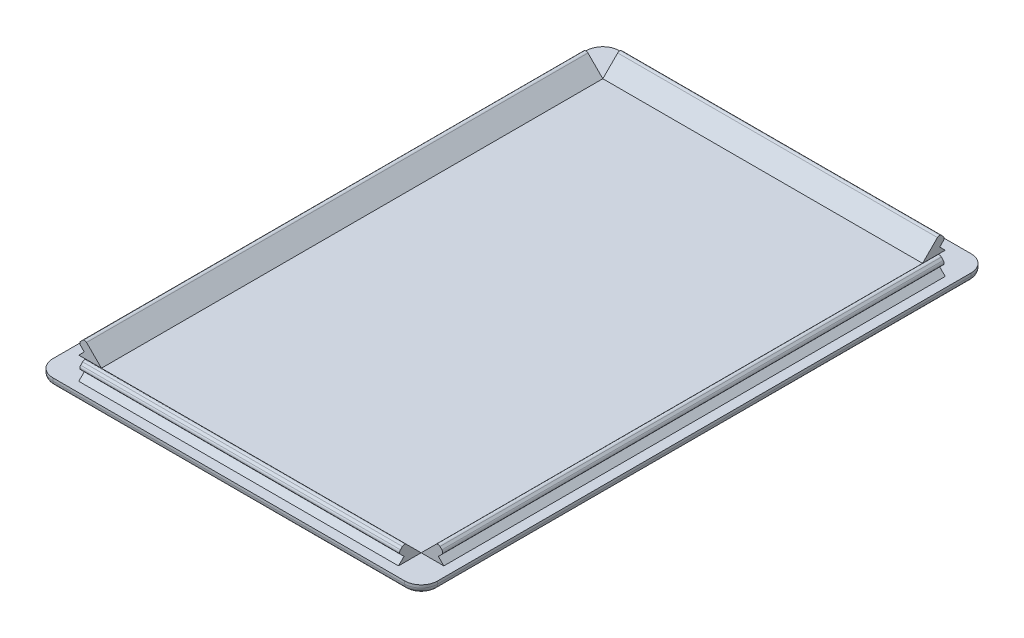
from build123d import *

# Parameters (mm, degrees)
EDIT_GLOBAL_VARIABLE_WITH_PCB_DIMENSIONS_W = 69.96
EDIT_GLOBAL_VARIABLE_WITH_PCB_DIMENSIONS_H = 102.98
BOSS_EXTRUDE1_DEPTH                        = 1.5
FILLET1_R                                  = 3
BOSS_EXTRUDE2_DEPTH                        = 91.1374
BOSS_EXTRUDE3_DEPTH                        = 91.1374
BOSS_EXTRUDE4_DEPTH                        = 58.1174
BOSS_EXTRUDE5_DEPTH                        = 58.1174
FILLET2_R                                  = 0.5
FILLET3_R                                  = 1


with BuildPart() as part:
    # EDIT GLOBAL VARIABLE WITH PCB DIMENSIONS → Boss-Extrude1 (new body)
    with BuildSketch(Plane(origin=(0, 0, 0), x_dir=(1, 0, 0), z_dir=(0, 1, 0))):
        Rectangle(EDIT_GLOBAL_VARIABLE_WITH_PCB_DIMENSIONS_W, EDIT_GLOBAL_VARIABLE_WITH_PCB_DIMENSIONS_H)
    extrude(amount=BOSS_EXTRUDE1_DEPTH)

    # Fillet1
    fillet1_edges = [part.edges().sort_by_distance(p)[0] for p in [
        (34.98, 0.75, 51.49),
        (-34.98, 0.75, 51.49),
        (-34.98, 0.75, -51.49),
        (34.98, 0.75, -51.49),
    ]]
    fillet(fillet1_edges, radius=FILLET1_R)

    # Sketch2 → Boss-Extrude2 (add)
    with BuildSketch(Plane.XY.offset(45.5687)):
        Polygon((33.18, 1.5), (29.058679656, 1.5), (32.119339828, 4.560660172), (33.18, 3.5), (32.18, 2.5), align=None)
    extrude(amount=-BOSS_EXTRUDE2_DEPTH)

    # Sketch3 → Boss-Extrude3 (add)
    with BuildSketch(Plane.XY.offset(45.5687)):
        Polygon((-33.18, 1.5), (-29.058679656, 1.5), (-32.119339828, 4.560660172), (-33.18, 3.5), (-32.18, 2.5), align=None)
    extrude(amount=-BOSS_EXTRUDE3_DEPTH)

    # Sketch4 → Boss-Extrude4 (add)
    with BuildSketch(Plane.ZY.offset(29.0587)):
        Polygon((-49.69, 1.5), (-45.568679656, 1.5), (-48.629339828, 4.560660172), (-49.69, 3.5), (-48.69, 2.5), align=None)
    extrude(amount=-BOSS_EXTRUDE4_DEPTH)

    # Sketch5 → Boss-Extrude5 (add)
    with BuildSketch(Plane.ZY.offset(29.0587)):
        Polygon((45.568679656, 1.5), (49.69, 1.5), (48.69, 2.5), (49.69, 3.5), (48.629339828, 4.560660172), align=None)
    extrude(amount=-BOSS_EXTRUDE5_DEPTH)

    # Fillet2
    fillet2_edges = [part.edges().sort_by_distance(p)[0] for p in [
        (33.18, 3.5, 0),
        (32.119339828, 4.560660172, 0),
        (-32.119339828, 4.560660172, 0),
        (-33.18, 3.5, 0),
        (0, 4.560660172, -48.629339828),
        (0, 3.5, -49.69),
        (0, 3.5, 49.69),
        (0, 4.560660172, 48.629339828),
    ]]
    fillet(fillet2_edges, radius=FILLET2_R)

    # Fillet3
    fillet3_edges = [part.edges().sort_by_distance(p)[0] for p in [
        (-34.98, 0, 0),
        (34.98, 0, 0),
        (0, 0, 51.49),
        (0, 0, -51.49),
        (-34.101320344, 0, 50.611320344),
        (34.101320344, 0, 50.611320344),
        (34.101320344, 0, -50.611320344),
        (-34.101320344, 0, -50.611320344),
    ]]
    fillet(fillet3_edges, radius=FILLET3_R)


solid = part.part
